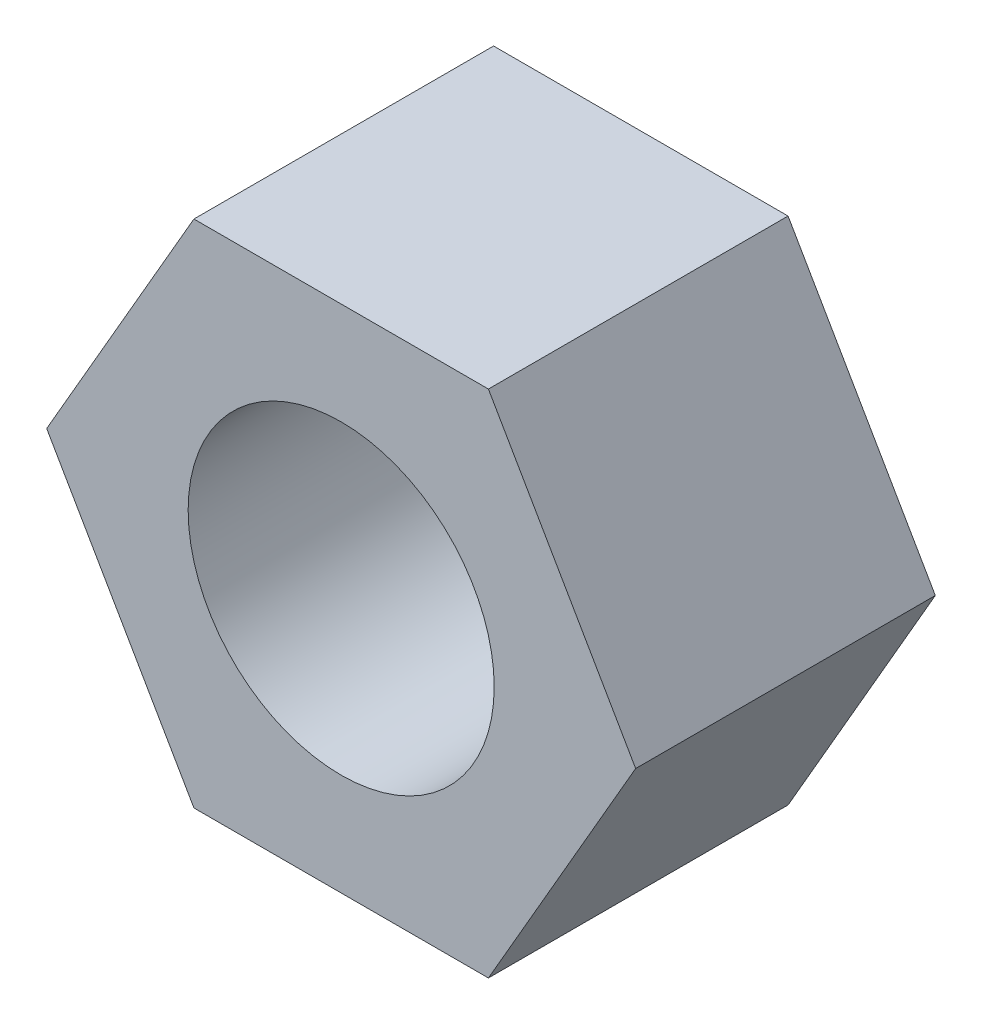
from build123d import *

# Parameters (mm, degrees)
BOSS_EXTRUDE1_DEPTH = 2.35
SKETCH2_R           = 2.4
CUT_EXTRUDE1_DEPTH  = 5.7


with BuildPart() as part:
    # Sketch1 → Boss-Extrude1 (new body, symmetric)
    with BuildSketch(Plane.XY):
        Polygon((4.618802154, 0), (2.309401077, 4), (-2.309401077, 4), (-4.618802154, 0), (-2.309401077, -4), (2.309401077, -4), align=None)
    extrude(amount=BOSS_EXTRUDE1_DEPTH, both=True)

    # Sketch2 → Cut-Extrude1 (cut, through all)
    with BuildSketch(Plane.XY.offset(2.35)):
        Circle(SKETCH2_R)
    extrude(amount=-CUT_EXTRUDE1_DEPTH, mode=Mode.SUBTRACT)


solid = part.part
